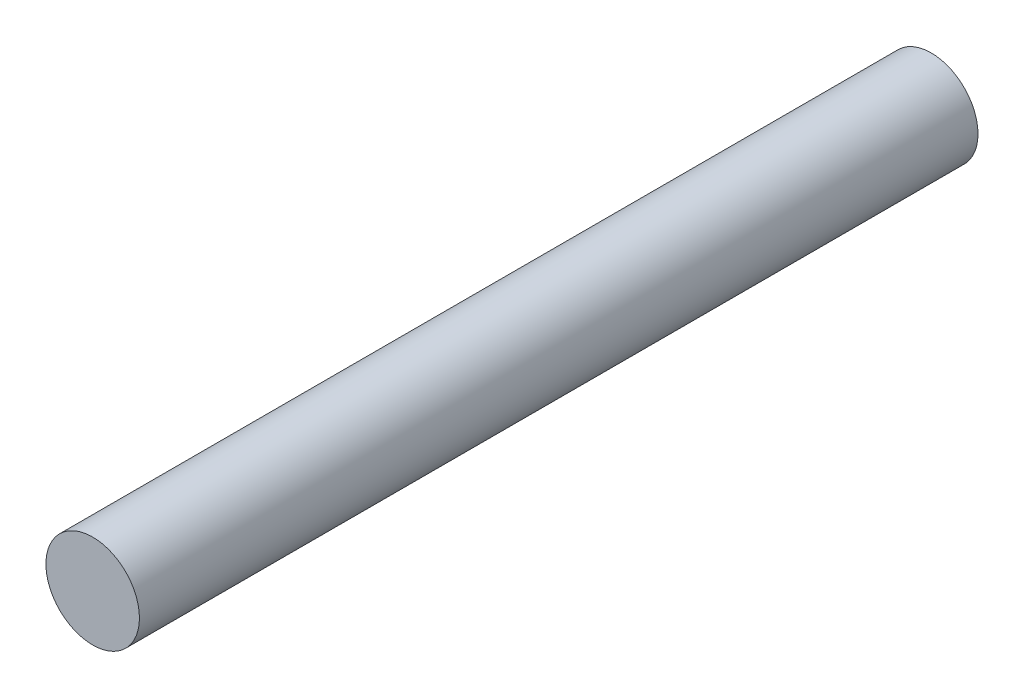
from build123d import *

# Parameters (mm, degrees)
SKETCH_1_R      = 4
EXTRUDE_1_DEPTH = 71.73


with BuildPart() as part:
    # 草图1 → 凸台-拉伸1 (new body)
    with BuildSketch(Plane.XY):
        with Locations((-7.895514891, 14.070478013)):
            Circle(SKETCH_1_R)
    extrude(amount=EXTRUDE_1_DEPTH)


solid = part.part
